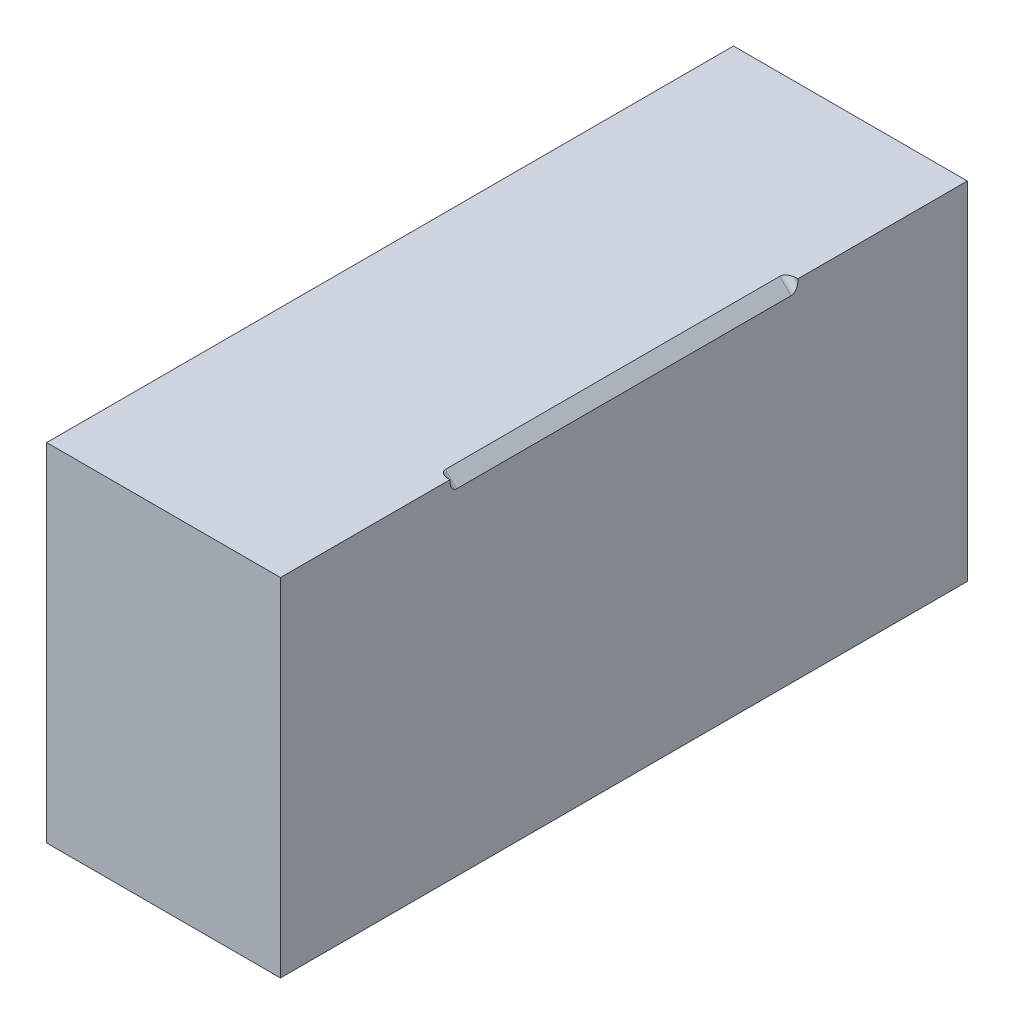
from build123d import *

# Parameters (mm, degrees)
SKIZZE1_W                       = 104.161525742
SKIZZE1_H                       = 154.506635072
AUFSATZ_LINEAR_AUSTRAGEN1_DEPTH = 153
SCHNITT_LINEAR_AUSTRAGEN1_DEPTH = 77.5
VERRUNDUNG3_R                   = 3


with BuildPart() as part:
    # Skizze1 → Aufsatz-Linear austragen1 (new body, symmetric)
    with BuildSketch(Plane.XY):
        Rectangle(SKIZZE1_W, SKIZZE1_H)
    extrude(amount=AUFSATZ_LINEAR_AUSTRAGEN1_DEPTH, both=True)

    # Skizze2 → Schnitt-Linear austragen1 (cut, symmetric)
    with BuildSketch(Plane.XY):
        Polygon((47.080762871, 77.253317536), (52.080762871, 77.253317536), (52.080762871, 72.253317536), align=None)
    extrude(amount=SCHNITT_LINEAR_AUSTRAGEN1_DEPTH, both=True, mode=Mode.SUBTRACT)

    # Verrundung3
    verrundung3_edges = [part.edges().sort_by_distance(p)[0] for p in [
        (49.580762871, 74.753317536, -77.5),
        (49.580762871, 74.753317536, 77.5),
    ]]
    fillet(verrundung3_edges, radius=VERRUNDUNG3_R)


solid = part.part
